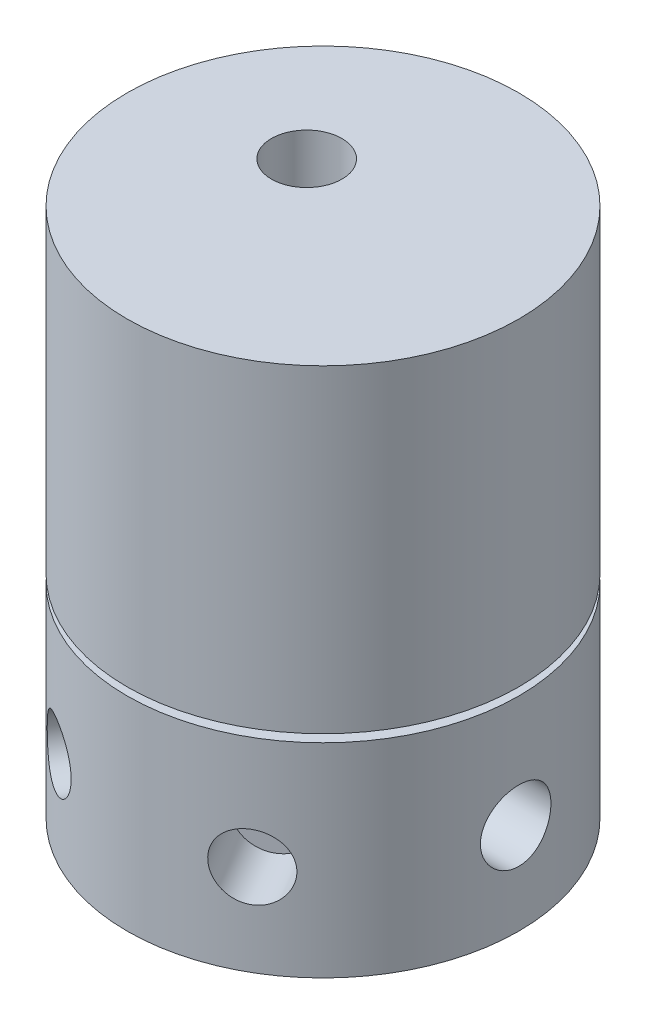
from build123d import *

# Parameters (mm, degrees)
SKETCH1_R           = 38.1
BOSS_EXTRUDE1_DEPTH = 39.624
SKETCH2_R           = 22.606
BOSS_EXTRUDE2_DEPTH = 12.7
SKETCH3_R           = 38.1
BOSS_EXTRUDE3_DEPTH = 61.976
CUT_EXTRUDE1_START  = 25.4
SKETCH4_R           = 6.858
CUT_EXTRUDE1_DEPTH  = 12.7
CUT_EXTRUDE2_START  = -25.4
SKETCH5_R           = 9.525
CUT_EXTRUDE2_DEPTH  = 12.7
SKETCH7_R           = 6.35
CUT_EXTRUDE3_DEPTH  = 12.7
SKETCH8_R           = 6.35
CUT_EXTRUDE5_DEPTH  = 12.7
SKETCH9_R           = 6.858
CUT_EXTRUDE6_DEPTH  = 12.7


with BuildPart() as part:
    # Sketch1 → Boss-Extrude1 (new body)
    with BuildSketch(Plane(origin=(0, 0, 0), x_dir=(1, 0, 0), z_dir=(0, 1, 0))):
        Circle(SKETCH1_R)
    extrude(amount=BOSS_EXTRUDE1_DEPTH)

    # Sketch2 → Boss-Extrude2 (add)
    with BuildSketch(Plane(origin=(0, 39.624, 0), x_dir=(1, 0, 0), z_dir=(0, 1, 0))):
        Circle(SKETCH2_R)
    extrude(amount=BOSS_EXTRUDE2_DEPTH)

    # Sketch3 → Boss-Extrude3 (add)
    with BuildSketch(Plane(origin=(0, 41.148, 0), x_dir=(1, 0, 0), z_dir=(0, 1, 0))):
        Circle(SKETCH3_R)
    extrude(amount=BOSS_EXTRUDE3_DEPTH)

    # Sketch4 → Cut-Extrude1 (cut)
    with BuildSketch(Plane(origin=(0, 0, 0), x_dir=(0, 0, -1), z_dir=(1, 0, 0)).offset(CUT_EXTRUDE1_START)):
        with Locations((0, 17.78)):
            Circle(SKETCH4_R)
    extrude(amount=CUT_EXTRUDE1_DEPTH, mode=Mode.SUBTRACT)

    # Sketch5 → Cut-Extrude2 (cut)
    with BuildSketch(Plane(origin=(0, 0, 0), x_dir=(0, 0, -1), z_dir=(1, 0, 0)).offset(CUT_EXTRUDE2_START)):
        with Locations((0, 17.78)):
            Circle(SKETCH5_R)
    extrude(amount=-CUT_EXTRUDE2_DEPTH, mode=Mode.SUBTRACT)

    # Sketch7 → Cut-Extrude3 (cut)
    with BuildSketch(Plane(origin=(-19.05, 0, 32.995567884), x_dir=(0.866025404, 0, 0.5), z_dir=(-0.5, 0, 0.866025404))):
        with Locations((0, 17.78)):
            Circle(SKETCH7_R)
    extrude(amount=-CUT_EXTRUDE3_DEPTH, mode=Mode.SUBTRACT)

    # Sketch8 → Cut-Extrude5 (cut)
    with BuildSketch(Plane(origin=(19.05, 0, 32.995567884), x_dir=(0.866025404, 0, -0.5), z_dir=(0.5, 0, 0.866025404))):
        with Locations((0, 17.78)):
            Circle(SKETCH8_R)
    extrude(amount=-CUT_EXTRUDE5_DEPTH, mode=Mode.SUBTRACT)

    # Sketch9 → Cut-Extrude6 (cut)
    with BuildSketch(Plane(origin=(0, 103.124, 0), x_dir=(1, 0, 0), z_dir=(0, 1, 0))):
        with Locations((-9.525, 6.35)):
            Circle(SKETCH9_R)
    extrude(amount=-CUT_EXTRUDE6_DEPTH, mode=Mode.SUBTRACT)


solid = part.part
